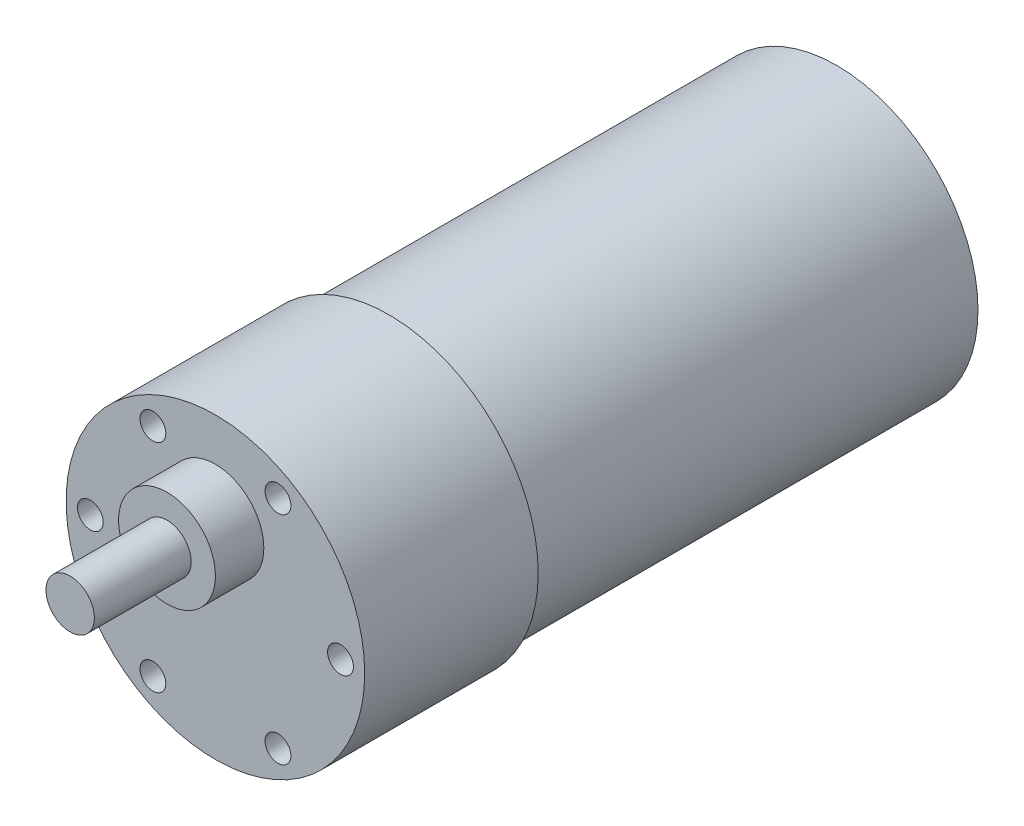
from build123d import *

# Parameters (mm, degrees)
ESBO_O1_R                = 18.5
RESSALTO_EXTRUS_O1_DEPTH = 21.5
ESBO_O2_R                = 17.5
RESSALTO_EXTRUS_O2_DEPTH = 55.5
ESBO_O5_R                = 6
RESSALTO_EXTRUS_O6_DEPTH = 6
ESBO_O6_R                = 3
RESSALTO_EXTRUS_O7_DEPTH = 12
ESBO_O7_R                = 1.6
CORTE_EXTRUS_O1_DEPTH    = 6


with BuildPart() as part:
    # Esboço1 → Ressalto-extrusão1 (new body)
    with BuildSketch(Plane.XY):
        Circle(ESBO_O1_R)
    extrude(amount=-RESSALTO_EXTRUS_O1_DEPTH)

    # Esboço2 → Ressalto-extrusão2 (add)
    with BuildSketch(Plane(origin=(0, 0, -21.5), x_dir=(-1, 0, 0), z_dir=(0, 0, -1))):
        Circle(ESBO_O2_R)
    extrude(amount=RESSALTO_EXTRUS_O2_DEPTH)

    # Esboço5 → Ressalto-extrusão6 (add)
    with BuildSketch(Plane.XY):
        with Locations((0, 7.2)):
            Circle(ESBO_O5_R)
    extrude(amount=RESSALTO_EXTRUS_O6_DEPTH)

    # Esboço6 → Ressalto-extrusão7 (add)
    with BuildSketch(Plane.XY.offset(6)):
        with Locations((0, 7.2)):
            Circle(ESBO_O6_R)
    extrude(amount=RESSALTO_EXTRUS_O7_DEPTH)

    # Esboço7 → Corte-extrusão1 (cut)
    with BuildSketch(Plane.XY):
        with Locations((-7.75, 13.423393759)):
            Circle(ESBO_O7_R)
        with Locations((7.75, 13.423393759)):
            Circle(ESBO_O7_R)
        with Locations((15.5, 0)):
            Circle(ESBO_O7_R)
        with Locations((7.75, -13.423393759)):
            Circle(ESBO_O7_R)
        with Locations((-7.75, -13.423393759)):
            Circle(ESBO_O7_R)
        with Locations((-15.5, 0)):
            Circle(ESBO_O7_R)
    extrude(amount=-CORTE_EXTRUS_O1_DEPTH, mode=Mode.SUBTRACT)


solid = part.part
